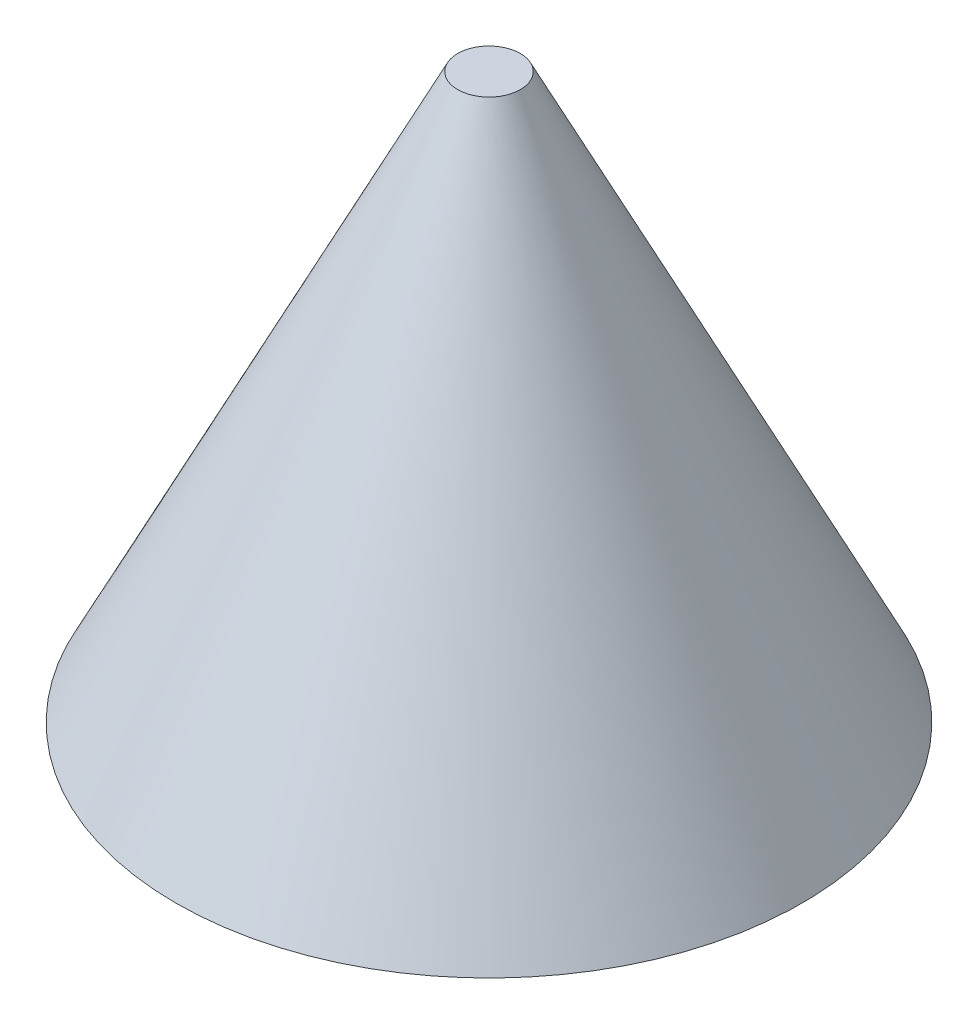
from build123d import *

# Parameters (mm, degrees)
CUT_EXTRUDE_START   = -9
SKETCH_2_R          = 0.5
CUT_EXTRUDE_1_DEPTH = 10
SKETCH_3_R          = 2.5
CUT_EXTRUDE_2_DEPTH = 3


with BuildPart() as part:
    # 草图1 → 旋转1 (revolve)
    with BuildSketch(Plane.XY):
        Polygon((0, 0), (5, 0), (0, 10), align=None)
    revolve(axis=Axis((0, 0, 0), (0, 1, 0)))

    # 草图2 → 切除-拉伸1 (cut)
    with BuildSketch(Plane.XZ.offset(CUT_EXTRUDE_START)):
        Circle(SKETCH_2_R)
    extrude(amount=-CUT_EXTRUDE_1_DEPTH, mode=Mode.SUBTRACT)

    # 草图3 → 切除-拉伸2 (cut)
    with BuildSketch(Plane.XZ):
        Circle(SKETCH_3_R)
    extrude(amount=-CUT_EXTRUDE_2_DEPTH, mode=Mode.SUBTRACT)


solid = part.part
